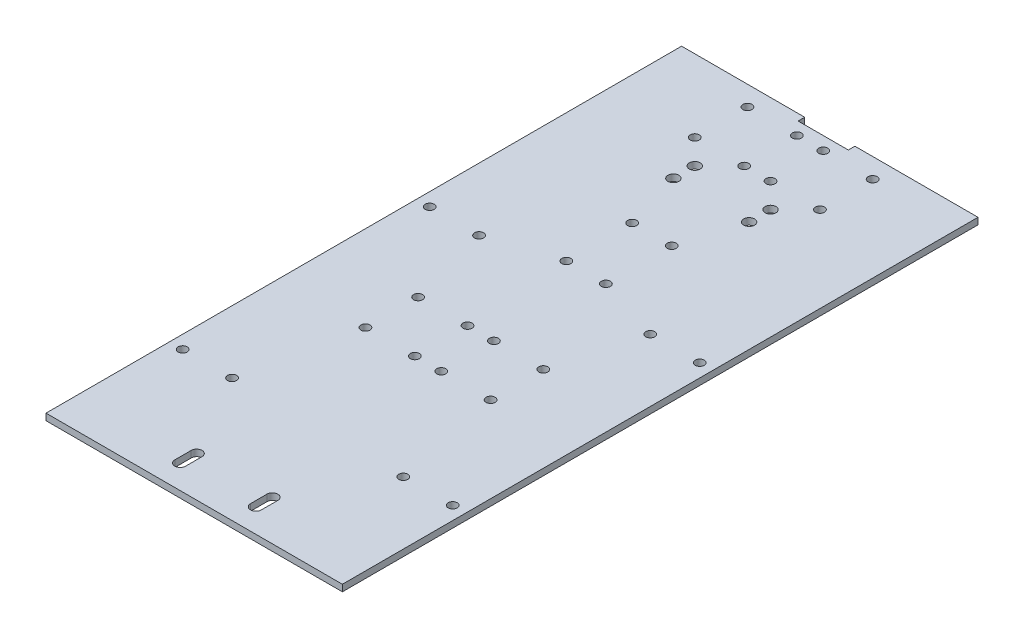
from build123d import *

# Parameters (mm, degrees)
EXTRUDE_1_DEPTH         = 4
HOLE_WIZARD_5_5_5_5_2_D = 5.5
HOLE_WIZARD_5_5_5_5_1_D = 5.5
HOLE_WIZARD_6_6_6_6_1_D = 6.6
CUT_EXTRUDE_1_DEPTH     = 5


with BuildPart() as part:
    # Эскиз1 → Бобышка-Вытянуть1 (new body)
    with BuildSketch(Plane(origin=(0, 0, 0), x_dir=(1, 0, 0), z_dir=(0, 1, 0))):
        Polygon((0, 386), (74.75, 386), (74.75, 382), (105.25, 382), (105.25, 386), (180, 386), (180, 0), (0, 0), align=None)
    extrude(amount=EXTRUDE_1_DEPTH)

    # Диаметр отверстия Ø5.5 (5.5)2 (through all)
    with Locations(Plane(origin=(0, 4, 0), x_dir=(1, 0, 0), z_dir=(0, 1, 0))):
        with Locations((78, 238), (78, 278), (102, 238), (102, 278), (128, 174), (128, 142), (98, 142), (98, 174), (128, 374), (98, 374), (128, 342), (98, 342), (52, 174), (52, 142), (82, 142), (82, 174), (52, 342), (82, 342), (52, 374), (82, 374)):
            Hole(HOLE_WIZARD_5_5_5_5_2_D / 2)

    # Диаметр отверстия Ø5.5 (5.5)1 (through all)
    with Locations(Plane(origin=(0, 4, 0), x_dir=(1, 0, 0), z_dir=(0, 1, 0))):
        with Locations((8, 75), (8, 225), (172, 225), (172, 75), (38, 225), (38, 75), (142, 225), (142, 75)):
            Hole(HOLE_WIZARD_5_5_5_5_1_D / 2)

    # Диаметр отверстия Ø6.6 (6.6)1 (through all)
    with Locations(Plane(origin=(0, 4, 0), x_dir=(1, 0, 0), z_dir=(0, 1, 0))):
        with Locations((67, 327), (113, 327), (67, 314), (113, 314)):
            Hole(HOLE_WIZARD_6_6_6_6_1_D / 2)

    # Эскиз8 → Вырез-Вытянуть1 (cut, through all)
    with BuildSketch(Plane(origin=(0, 4, 0), x_dir=(1, 0, 0), z_dir=(0, 1, 0))):
        with BuildLine():
            Line((70.3, 24.5), (70.3, 14.5))
            ThreePointArc((70.3, 14.5), (67, 11.2), (63.7, 14.5))
            Line((63.7, 14.5), (63.7, 24.5))
            ThreePointArc((63.7, 24.5), (67, 27.8), (70.3, 24.5))
        make_face()
        with BuildLine():
            Line((109.7, 14.5), (109.7, 24.5))
            ThreePointArc((109.7, 24.5), (113, 27.8), (116.3, 24.5))
            Line((116.3, 24.5), (116.3, 14.5))
            ThreePointArc((116.3, 14.5), (113, 11.2), (109.7, 14.5))
        make_face()
    extrude(amount=-CUT_EXTRUDE_1_DEPTH, mode=Mode.SUBTRACT)


solid = part.part
